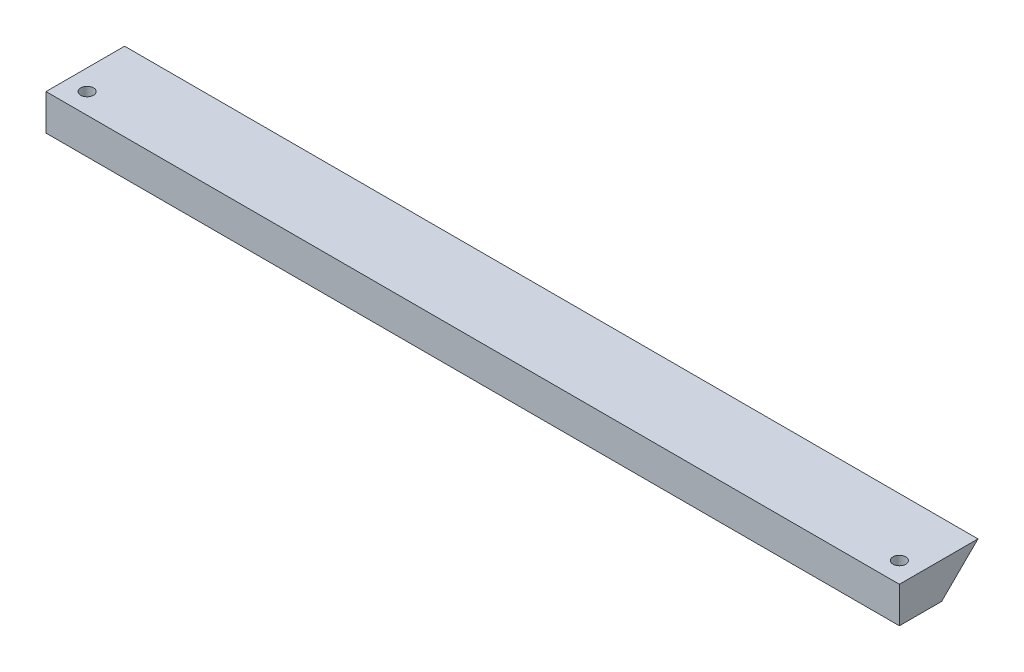
from build123d import *

# Parameters (mm, degrees)
BOSS_EXTRUDE1_DEPTH   = 83
M3X0_5_TAPPED_HOLE1_D = 2.5


with BuildPart() as part:
    # Sketch2 → Boss-Extrude1 (new body, symmetric)
    with BuildSketch(Plane(origin=(0, 0, 0), x_dir=(0, 0, -1), z_dir=(1, 0, 0))):
        Polygon((0, 0), (15.29, 0), (8.22, -7), (0, -7), align=None)
    extrude(amount=BOSS_EXTRUDE1_DEPTH, both=True)

    # M3x0.5 Tapped Hole1 (through all)
    with Locations(Plane(origin=(0, -7, 0), x_dir=(-1, 0, 0), z_dir=(0, -1, 0))):
        with Locations((79, 4), (-79, 4)):
            Hole(M3X0_5_TAPPED_HOLE1_D / 2)


solid = part.part
